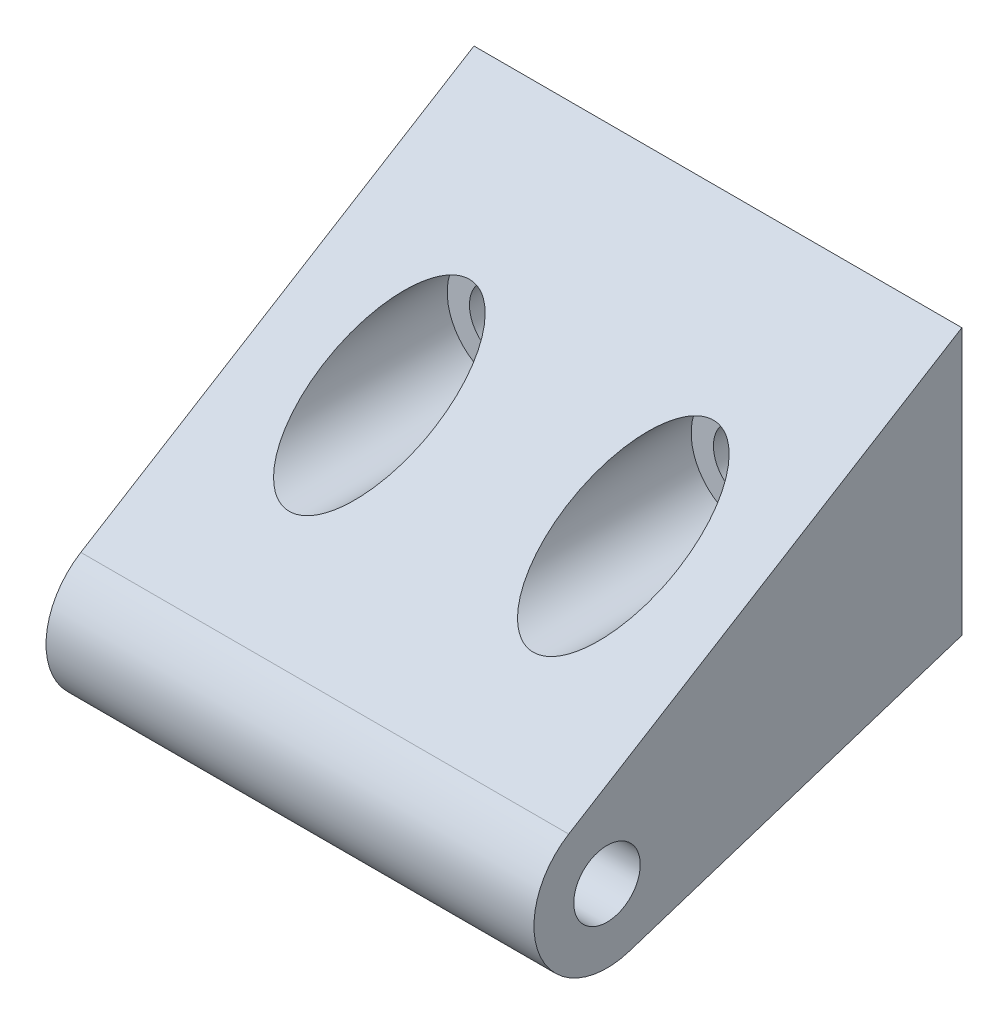
from build123d import *

# Parameters (mm, degrees)
SKETCH1_R           = 1.20904
BOSS_EXTRUDE1_DEPTH = 17.74444
SKETCH5_R           = 2.01676
CUT_EXTRUDE5_DEPTH  = 12.17243946
SKETCH6_R           = 1.20904
CUT_EXTRUDE6_DEPTH  = 4.39014054


with BuildPart() as part:
    # Sketch1 → Boss-Extrude1 (new body)
    with BuildSketch(Plane(origin=(0, 0, 0), x_dir=(0, 0, -1), z_dir=(1, 0, 0))):
        with BuildLine():
            Line((15.56258, 11.0617), (15.56258, 1.3716))
            Line((15.56258, 1.3716), (3.472518261, -2.528530751))
            ThreePointArc((3.472518261, -2.528530751), (0.243922332, -1.11203737), (1.264385716, 2.262712941))
            Line((1.264385716, 2.262712941), (15.56258, 11.0617))
        make_face()
        with Locations((2.65684, 0)):
            Circle(SKETCH1_R, mode=Mode.SUBTRACT)
    extrude(amount=-BOSS_EXTRUDE1_DEPTH)

    # Sketch5 → Cut-Extrude5 (cut)
    with BuildSketch(Plane.XY):
        with Locations((-13.3096, 6.21538)):
            Circle(SKETCH5_R)
        with Locations((-4.43738, 6.21538)):
            Circle(SKETCH5_R)
    extrude(amount=-CUT_EXTRUDE5_DEPTH, mode=Mode.SUBTRACT)

    # Sketch6 → Cut-Extrude6 (cut, through all)
    with BuildSketch(Plane.XY.offset(-12.17243946)):
        with Locations((-13.3096, 6.21538)):
            Circle(SKETCH6_R)
        with Locations((-4.43738, 6.21538)):
            Circle(SKETCH6_R)
    extrude(amount=-CUT_EXTRUDE6_DEPTH, mode=Mode.SUBTRACT)


solid = part.part
